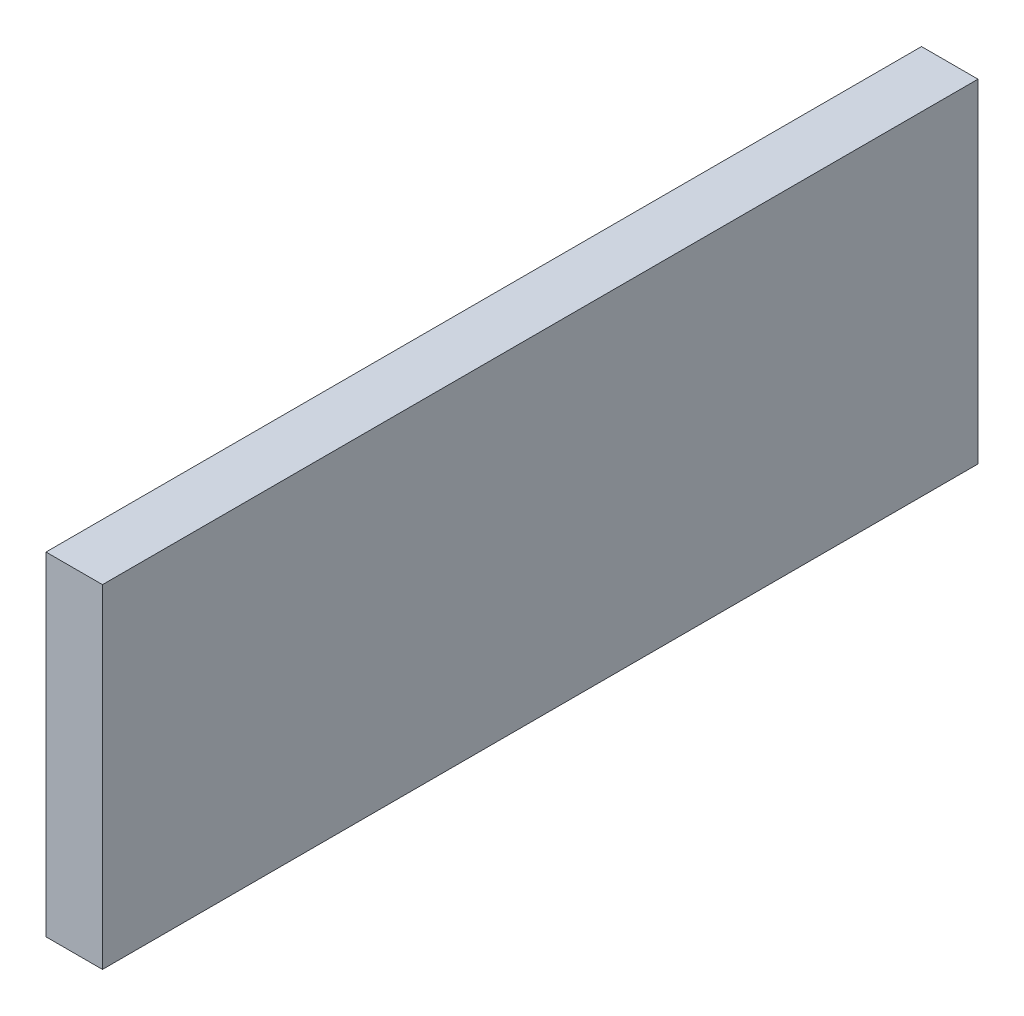
from build123d import *

# Parameters (mm, degrees)
SKETCH1_W      = 10
SKETCH1_H      = 59
EXTRUDE1_DEPTH = 155


with BuildPart() as part:
    # Sketch1 → Extrude1 (new body)
    with BuildSketch(Plane.XY):
        Rectangle(SKETCH1_W, SKETCH1_H)
    extrude(amount=EXTRUDE1_DEPTH)


solid = part.part
